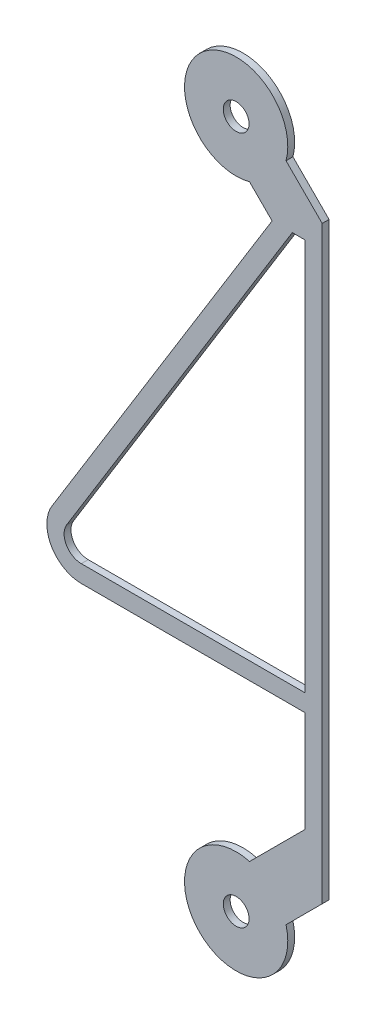
from build123d import *

# Parameters (mm, degrees)
SKETCH1_R           = 0.375
BOSS_EXTRUDE1_DEPTH = 0.1


with BuildPart() as part:
    # Sketch1 → Boss-Extrude1 (new body, symmetric)
    with BuildSketch(Plane.XY):
        with BuildLine():
            Line((1.04409719, 7.895242639), (-5.351162932, -2.475098425))
            ThreePointArc((-5.351162932, -2.475098425), (-5.37318428, -3.487390206), (-4.5, -4))
            Line((-4.5, -4), (2, -4))
            Line((2, -4), (2, -6.939339828))
            Line((2, -6.939339828), (0.388228568, -8.551111261))
            ThreePointArc((0.388228568, -8.551111261), (-1.060660172, -11.060660172), (1.448888739, -9.611771432))
            Line((1.448888739, -9.611771432), (2.5, -8.560660172))
            Line((2.5, -8.560660172), (2.5, 8.560660172))
            Line((2.5, 8.560660172), (1.448888739, 9.611771432))
            ThreePointArc((1.448888739, 9.611771432), (-1.060660172, 11.060660172), (0.388228568, 8.551111261))
            Line((0.388228568, 8.551111261), (1.04409719, 7.895242639))
        make_face()
        with Locations((0, 10)):
            Circle(SKETCH1_R, mode=Mode.SUBTRACT)
        with Locations((0, -10)):
            Circle(SKETCH1_R, mode=Mode.SUBTRACT)
        with BuildLine():
            Line((1.631528786, 7.895242639), (-4.925581466, -2.737549213))
            ThreePointArc((-4.925581466, -2.737549213), (-4.93659214, -3.243695103), (-4.5, -3.5))
            Line((-4.5, -3.5), (2, -3.5))
            Line((2, -3.5), (2, 7.895242639))
            Line((2, 7.895242639), (1.631528786, 7.895242639))
        make_face(mode=Mode.SUBTRACT)
    extrude(amount=BOSS_EXTRUDE1_DEPTH, both=True)


solid = part.part
